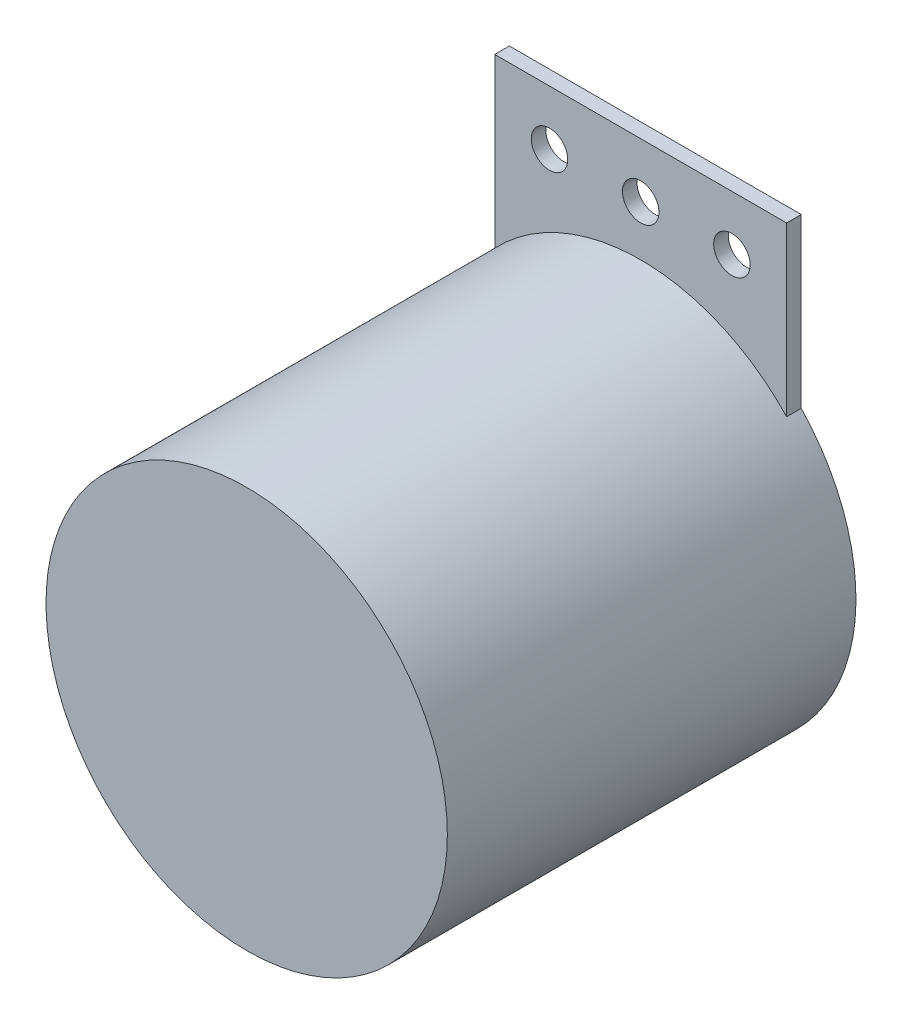
from build123d import *

# Parameters (mm, degrees)
SKETCH_1_R          = 27.5
EXTRUDE_1_DEPTH     = 56
SKETCH_2_W          = 40
SKETCH_2_H          = 23
EXTRUDE_2_DEPTH     = 2
SKETCH_3_R          = 2.5
CUT_EXTRUDE_1_DEPTH = 2


with BuildPart() as part:
    # 草图1 → 凸台-拉伸1 (new body)
    with BuildSketch(Plane.XY):
        Circle(SKETCH_1_R)
    extrude(amount=EXTRUDE_1_DEPTH)

    # 草图2 → 凸台-拉伸2 (add)
    with BuildSketch(Plane(origin=(0, 0, 0), x_dir=(-1, 0, 0), z_dir=(0, 0, -1))):
        with Locations((0, 30.374586088)):
            Rectangle(SKETCH_2_W, SKETCH_2_H)
    extrude(amount=-EXTRUDE_2_DEPTH)

    # 草图3 → 切除-拉伸1 (cut)
    with BuildSketch(Plane.XY.offset(2)):
        with Locations((0, 34.374586088)):
            Circle(SKETCH_3_R)
        with Locations((-12.5, 34.374586088)):
            Circle(SKETCH_3_R)
        with Locations((12.5, 34.374586088)):
            Circle(SKETCH_3_R)
    extrude(amount=-CUT_EXTRUDE_1_DEPTH, mode=Mode.SUBTRACT)


solid = part.part
